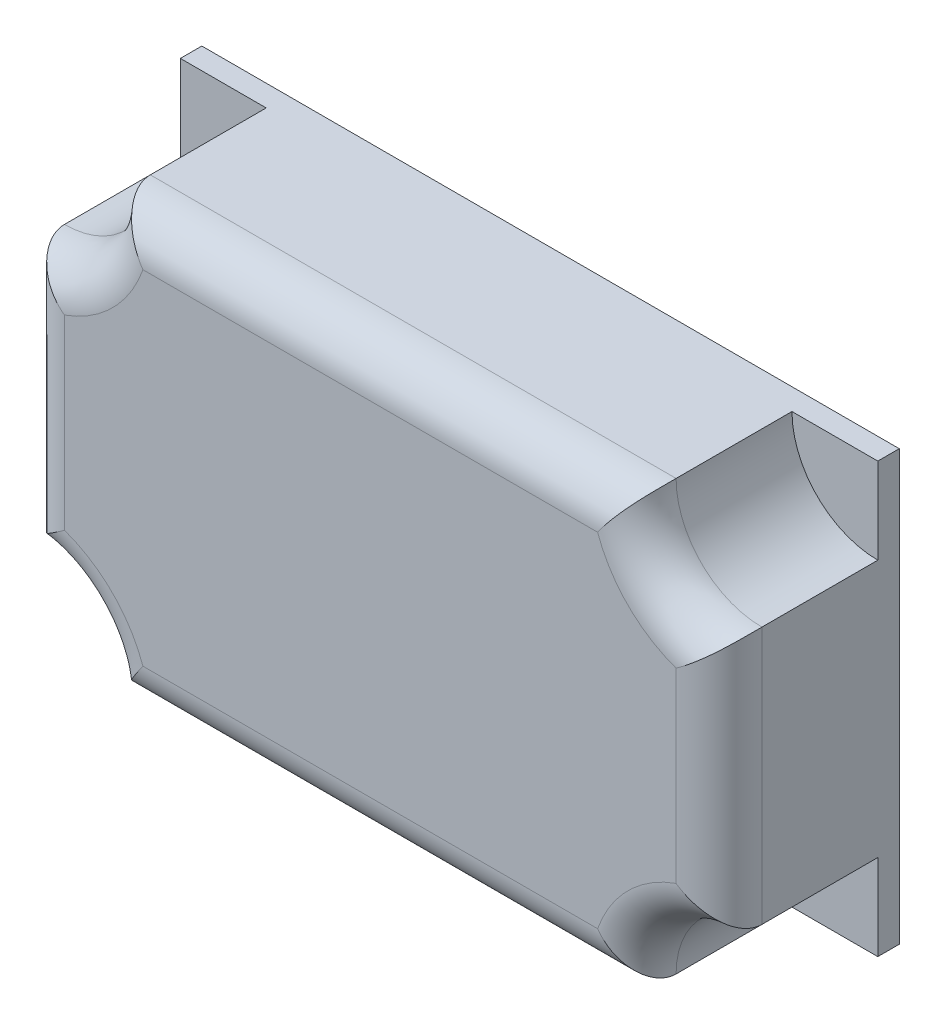
from build123d import *

# Parameters (mm, degrees)
BOSS_EXTRUDE1_DEPTH = 14.8
SKETCH1_3_W         = 65
SKETCH1_3_H         = 40
BOSS_EXTRUDE2_DEPTH = 2
FILLET1_R           = 4


with BuildPart() as part:
    # Sketch1 → Boss-Extrude1 (new body)
    with BuildSketch(Plane.XY):
        with BuildLine():
            ThreePointArc((-29.158352439, 21.804727646), (-31.501498189, 16.147873397), (-37.158352439, 13.804727646))
            Line((-37.158352439, 13.804727646), (-37.158352439, -10.195272354))
            ThreePointArc((-37.158352439, -10.195272354), (-31.501498189, -12.538418104), (-29.158352439, -18.195272354))
            Line((-29.158352439, -18.195272354), (19.841647561, -18.195272354))
            ThreePointArc((19.841647561, -18.195272354), (22.184793312, -12.538418104), (27.841647561, -10.195272354))
            Line((27.841647561, -10.195272354), (27.841647561, 13.804727646))
            ThreePointArc((27.841647561, 13.804727646), (22.184793312, 16.147873397), (19.841647561, 21.804727646))
            Line((19.841647561, 21.804727646), (-29.158352439, 21.804727646))
        make_face()
    extrude(amount=BOSS_EXTRUDE1_DEPTH)

    # Sketch1_3 → Boss-Extrude2 (add)
    with BuildSketch(Plane.XY):
        with Locations((-4.658352439, 1.804727646)):
            Rectangle(SKETCH1_3_W, SKETCH1_3_H)
    extrude(amount=-BOSS_EXTRUDE2_DEPTH)

    # Fillet1
    fillet1_edges = [part.edges().sort_by_distance(p)[0] for p in [
        (-4.658352439, -18.195272354, 14.8),
        (-31.501498189, -12.538418104, 14.8),
        (-37.158352439, 1.804727646, 14.8),
        (-31.501498189, 16.147873397, 14.8),
        (-4.658352439, 21.804727646, 14.8),
        (22.184793312, 16.147873397, 14.8),
        (27.841647561, 1.804727646, 14.8),
        (22.184793312, -12.538418104, 14.8),
    ]]
    fillet(fillet1_edges, radius=FILLET1_R)


solid = part.part
